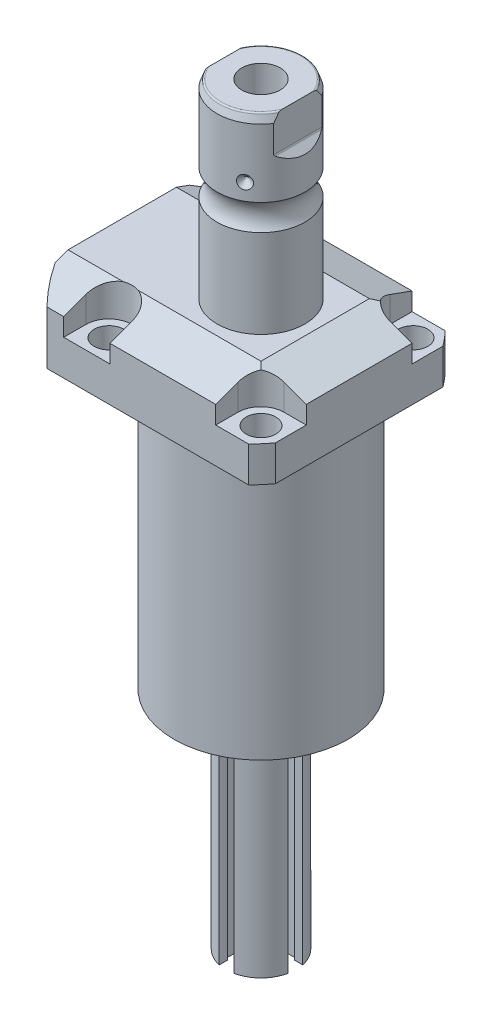
from build123d import *

# Parameters (mm, degrees)
SKETCH1_W                   = 70.866
SKETCH1_H                   = 85.496
EXTRUDE1_DEPTH              = 122.047
SKETCH2_OUTSIDE_W           = 120.498
SKETCH2_OUTSIDE_H           = 105.868
SKETCH2_OUTSIDE_R           = 50.8
CUT_EXTRUDE1_DEPTH          = 123.047
SKETCH3_W                   = 45.1992
SKETCH3_H                   = 97.028
FILLET1_R                   = 0.381
CUT_EXTRUDE2_DEPTH          = 12.243
CUT_EXTRUDE9_START          = -51.063
CUT_EXTRUDE9_DEPTH          = 87.496
CUT_EXTRUDE7_DEPTH          = 36.433
CUT_EXTRUDE7_DEPTH_BACK     = 36.433
SKETCH10_R                  = 1.1811
SKETCH17_W                  = 5.3594
SKETCH17_H                  = 12.776
HOLE1_AT_2_COUNT            = 2
HOLE1_AT_2_PITCH            = 54.864
HOLE1_AT_3_COUNT            = 2
HOLE1_AT_3_PITCH            = 77.589412886
HOLE1_AT_4_COUNT            = 2
HOLE1_AT_4_PITCH            = 54.864
CHAMFER1_SIZE               = 0.635
FILLET2_R                   = 0.635
CIRPATTERN1_COUNT           = 3
CUT_EXTRUDE10_DEPTH         = 36.433
CUT_EXTRUDE10_DEPTH_BACK    = 36.433
SKETCH31_R                  = 1.727203454
SKETCH31_R_2                = 1.727
CUT_EXTRUDE11_DEPTH         = 99.568005
SKETCH32_R                  = 2.705
SKETCH32_R_2                = 2.70510541
EXTRUDE2_DEPTH              = 2.946405893
CUT_EXTRUDE12_DEPTH         = 2.032004064
CUT_EXTRUDE13_DEPTH         = 6.477012954
SKETCH35_W                  = 6.98501397
SKETCH35_H                  = 70.612141224
CUT_EXTRUDE14_DEPTH         = 3.302006604
CIRPATTERN2_COUNT           = 2
CIRPATTERN2_ANGLE           = 90
CIRPATTERN2_COPY_1_DEPTH    = 6.477012954
CIRPATTERN2_COPY_2_SKETCH_W = 6.98501397
CIRPATTERN2_COPY_2_SKETCH_H = 70.612141224
CIRPATTERN2_COPY_2_DEPTH    = 3.302006604


with BuildPart() as part:
    # Sketch1 → Extrude1 (new body)
    with BuildSketch(Plane(origin=(0, 0, 0), x_dir=(0, 0, 1), z_dir=(0, -1, 0))):
        with Locations((0, 7.315)):
            Rectangle(SKETCH1_W, SKETCH1_H)
    extrude(amount=-EXTRUDE1_DEPTH)

    # Sketch2 outside → Cut-Extrude1 (cut, through all)
    with BuildSketch(Plane.XZ):
        with Locations((-7.315, 0)):
            Rectangle(SKETCH2_OUTSIDE_W, SKETCH2_OUTSIDE_H)
        with Locations((-5.4102, 0)):
            Circle(SKETCH2_OUTSIDE_R, mode=Mode.SUBTRACT)
    extrude(amount=-CUT_EXTRUDE1_DEPTH, mode=Mode.SUBTRACT)

    # Sketch3 → Cut-Revolve1 (revolve, cut)
    with BuildSketch(Plane(origin=(0, 0, 0), x_dir=(0, 0, -1), z_dir=(1, 0, 0))):
        with Locations((53.9941, 48.514)):
            Rectangle(SKETCH3_W, SKETCH3_H)
    revolve(axis=Axis((0, -93.345, 0), (0, 1, 0)), mode=Mode.SUBTRACT)

    # Fillet1
    fillet1_edges = [part.edges().sort_by_distance(p)[0] for p in [
        (0, 97.028, 31.3945),
    ]]
    fillet(fillet1_edges, radius=FILLET1_R)

    # Sketch4 → Cut-Extrude2 (cut)
    with BuildSketch(Plane(origin=(0, 122.047, 0), x_dir=(-1, 0, 0), z_dir=(0, 1, 0))):
        with BuildLine():
            Line((-19.1008, -35.433), (-19.1008, -27.432))
            ThreePointArc((-19.1008, -27.432), (-21.540951985, -21.540951985), (-27.432, -19.1008))
            Line((-27.432, -19.1008), (-35.433, -19.1008))
            Line((-35.433, -19.1008), (-35.433, -35.433))
            Line((-35.433, -35.433), (-19.1008, -35.433))
        make_face()
        with BuildLine():
            Line((35.7632, -35.433), (19.1008, -35.433))
            Line((19.1008, -35.433), (19.1008, -27.432))
            ThreePointArc((19.1008, -27.432), (27.432, -19.1008), (35.7632, -27.432))
            Line((35.7632, -27.432), (35.7632, -35.433))
        make_face()
        with BuildLine():
            Line((19.1008, 35.433), (19.1008, 27.432))
            ThreePointArc((19.1008, 27.432), (27.432, 19.1008), (35.7632, 27.432))
            Line((35.7632, 27.432), (35.7632, 35.433))
            Line((35.7632, 35.433), (19.1008, 35.433))
        make_face()
        with BuildLine():
            Line((-27.432, 19.1008), (-35.433, 19.1008))
            Line((-35.433, 19.1008), (-35.433, 35.433))
            Line((-35.433, 35.433), (-19.1008, 35.433))
            Line((-19.1008, 35.433), (-19.1008, 27.432))
            ThreePointArc((-19.1008, 27.432), (-21.540951985, 21.540951985), (-27.432, 19.1008))
        make_face()
    extrude(amount=-CUT_EXTRUDE2_DEPTH, mode=Mode.SUBTRACT)

    # Sketch5 → Cut-Extrude9 (cut)
    with BuildSketch(Plane(origin=(0, 0, 0), x_dir=(0, 0, -1), z_dir=(1, 0, 0)).offset(CUT_EXTRUDE9_START)):
        Polygon((-19.558, 122.047), (-35.433, 116.268972531), (-35.433, 122.047), align=None)
    cut_extrude9 = extrude(amount=CUT_EXTRUDE9_DEPTH, mode=Mode.SUBTRACT)

    # Mirror1: Cut-Extrude9 across plane
    add(cut_extrude9.mirror(Plane.XY), mode=Mode.SUBTRACT)

    # Sketch9 → Cut-Extrude7 (cut, two sides)
    with BuildSketch(Plane.XY) as cut_extrude7_sk:
        Polygon((19.558, 122.047), (35.433, 116.268972531), (35.433, 122.047), align=None)
    extrude(amount=CUT_EXTRUDE7_DEPTH, mode=Mode.SUBTRACT)
    extrude(cut_extrude7_sk.sketch, amount=-CUT_EXTRUDE7_DEPTH_BACK, mode=Mode.SUBTRACT)

    # Sketch20 → Cut-Revolve4 (revolve, cut)
    with BuildSketch(Plane(origin=(-35.0774, 88.9, -18.1102), x_dir=(0, 1, 0), z_dir=(1, 0, 0)), mode=Mode.PRIVATE) as cut_revolve4_sk:
        Polygon((8.128, 38.3413), (9.5758, 38.3413), (9.5758, 35.8902), (10.5918, 35.8902), (10.5918, 33.8836), (21.5646, 33.8836), (21.5646, 32.639), (8.128, 32.639), align=None)
    cut_revolve4 = revolve(cut_revolve4_sk.sketch.rotate(Axis((-35.0774, 81.620304954, 14.5288), (0, 1, 0)), 180), axis=Axis((-35.0774, 81.620304954, 14.5288), (0, 1, 0)), mode=Mode.SUBTRACT)  # turned: the seam where the file's is

    # Mirror10: Cut-Revolve4 across plane
    add(cut_revolve4.mirror(Plane.XY), mode=Mode.SUBTRACT)

    # Sketch15 → Revolve3 (revolve)
    with BuildSketch(Plane(origin=(0, 0, 0), x_dir=(0, 0, -1), z_dir=(1, 0, 0)), mode=Mode.PRIVATE) as revolve3_sk:
        with BuildLine():
            Line((0, 122.047), (15.875, 122.047))
            Line((15.875, 122.047), (15.875, 153.87790643))
            ThreePointArc((15.875, 153.87790643), (14.3256, 158.585), (15.875, 163.29209357))
            Line((15.875, 163.29209357), (15.875, 187.76999416))
            Line((15.875, 187.76999416), (14.81184082, 190.691))
            Line((14.81184082, 190.691), (0, 190.691))
            Line((0, 190.691), (0, 122.047))
        make_face()
    revolve(revolve3_sk.sketch.rotate(Axis((0, 250.290824608, 0), (0, -1, 0)), 180), axis=Axis((0, 250.290824608, 0), (0, -1, 0)))  # turned: the seam where the file's is

    # Sketch17 → Hole1 (revolve, cut)
    with BuildSketch(Plane(origin=(27.432, 109.804, -27.432), x_dir=(0, 0, 1), z_dir=(1, 0, 0))):
        with Locations((2.6797, 6.388)):
            Rectangle(SKETCH17_W, SKETCH17_H)
    hole1 = revolve(axis=Axis((27.432, -0.196, -27.432), (0, 1, 0)), mode=Mode.SUBTRACT)

    # Hole1 at 2: Hole1 ×2
    with Locations(*[(0, 0, i * HOLE1_AT_2_PITCH) for i in range(1, HOLE1_AT_2_COUNT)]):
        add(hole1, mode=Mode.SUBTRACT)

    # Hole1 at 3: Hole1 ×2
    with Locations(*[Vector(-0.707106781, 0, 0.707106781) * (i * HOLE1_AT_3_PITCH) for i in range(1, HOLE1_AT_3_COUNT)]):
        add(hole1, mode=Mode.SUBTRACT)

    # Hole1 at 4: Hole1 ×2
    with Locations(*[(-i * HOLE1_AT_4_PITCH, 0, 0) for i in range(1, HOLE1_AT_4_COUNT)]):
        add(hole1, mode=Mode.SUBTRACT)

    # Chamfer1
    chamfer1_edges = [part.edges().sort_by_distance(p)[0] for p in [
        (-35.0774, 99.4918, 15.7734),
        (-35.0774, 99.4918, -15.7734),
    ]]
    chamfer(chamfer1_edges, length=CHAMFER1_SIZE)

    # Sketch21 → Cut-Revolve5 (revolve, cut)
    with BuildSketch(Plane.XZ.offset(-110.0328)):
        Polygon((-50.063, -1.9304), (-49.809, -1.9304), (-49.809, -6.3246), (-49.0978, -7.0358), (-35.6358, -7.0358), (-35.6358, -12.9794), (-50.063, -12.9794), align=None)
    cut_revolve5 = revolve(axis=Axis((-57.549532301, 110.0328, -12.9794), (1, 0, 0)), mode=Mode.SUBTRACT)

    # Mirror13: Cut-Revolve5 across plane
    add(cut_revolve5.mirror(Plane.XY), mode=Mode.SUBTRACT)

    # Fillet2
    fillet2_edges = [part.edges().sort_by_distance(p)[0] for p in [
        (0, 190.691, -14.81184082),
    ]]
    fillet(fillet2_edges, radius=FILLET2_R)

    # Sketch26 → Cut-Revolve7 (revolve, cut)
    with BuildSketch(Plane.XY, mode=Mode.PRIVATE) as cut_revolve7_sk:
        Polygon((-15.875, 171.686), (-13.462, 169.273), (-15.875, 169.273), align=None)
    cut_revolve7 = revolve(cut_revolve7_sk.sketch.rotate(Axis((-39.772000707, 169.273, 0), (1, 0, 0)), 90), axis=Axis((-39.772000707, 169.273, 0), (1, 0, 0)), mode=Mode.SUBTRACT)  # turned: the seam where the file's is

    # CirPattern1: Cut-Revolve7 ×3 about axis
    cirpattern1_axis = Axis((0, 250.290824608, 0), (0, 1, 0))
    for i in range(1, CIRPATTERN1_COUNT):
        add(cut_revolve7.rotate(cirpattern1_axis, i * 360 / CIRPATTERN1_COUNT), mode=Mode.SUBTRACT)

    # Sketch27 → Hole2 (revolve, cut)
    with BuildSketch(Plane(origin=(0, 190.691, 0), x_dir=(0, 0, 1), z_dir=(1, 0, 0))):
        Polygon((0, 0), (0, 29.566487704), (6.9342, 25.4), (6.9342, 0), align=None)
    revolve(axis=Axis((0, 194.935199587, 0), (0, -1, 0)), mode=Mode.SUBTRACT)

    # Sketch29 → Cut-Extrude10 (cut, two sides)
    with BuildSketch(Plane.XY) as cut_extrude10_sk:
        with BuildLine():
            Line((13.284, 190.691), (13.284, 177.991))
            ThreePointArc((13.284, 177.991), (13.342003912, 177.699394643), (13.507185078, 177.452183558))
            Line((13.507185078, 177.452183558), (15.875, 175.084368636))
            Line((15.875, 175.084368636), (15.875, 190.691))
            Line((15.875, 190.691), (13.284, 190.691))
        make_face()
        with BuildLine():
            Line((-15.875, 190.691), (-13.284, 190.691))
            Line((-13.284, 190.691), (-13.284, 177.991))
            ThreePointArc((-13.284, 177.991), (-13.342003912, 177.699394643), (-13.507185078, 177.452183558))
            Line((-13.507185078, 177.452183558), (-15.875, 175.084368636))
            Line((-15.875, 175.084368636), (-15.875, 190.691))
        make_face()
    extrude(amount=CUT_EXTRUDE10_DEPTH, mode=Mode.SUBTRACT)
    extrude(cut_extrude10_sk.sketch, amount=-CUT_EXTRUDE10_DEPTH_BACK, mode=Mode.SUBTRACT)

    # Sketch30 → Revolve5 (revolve)
    with BuildSketch(Plane.XY, mode=Mode.PRIVATE) as revolve5_sk:
        Polygon((0, 0), (22.22504445, 0), (22.22504445, -2.54000508), (12.7000254, -2.54000508), (12.7000254, -81.28016256), (0, -81.28016256), align=None)
    revolve(revolve5_sk.sketch.rotate(Axis((0, -963.130914712, 0), (0, 1, 0)), 270), axis=Axis((0, -963.130914712, 0), (0, 1, 0)))  # turned: the seam where the file's is

    # Sketch31 → Cut-Extrude11 (cut)
    with BuildSketch(Plane.XZ.offset(2.54000508)):
        with Locations((19.431038862, 0)):
            Circle(SKETCH31_R)
        with Locations((16.827773276, 9.715519431)):
            Circle(SKETCH31_R_2)
        with Locations((9.715519431, 16.827773276)):
            Circle(SKETCH31_R_2)
        with Locations((0, 19.431038862)):
            Circle(SKETCH31_R_2)
        with Locations(Location((-9.715519431, 16.827773276, 0), (0, 0, 90))):  # turned: the seam where the file's is
            Circle(SKETCH31_R_2)
        with Locations(Location((-16.827773276, 9.715519431, 0), (0, 0, 90))):  # turned: the seam where the file's is
            Circle(SKETCH31_R_2)
        with Locations(Location((-19.431038862, 0, 0), (0, 0, 90))):  # turned: the seam where the file's is
            Circle(SKETCH31_R)
        with Locations(Location((16.827773276, -9.715519431, 0), (0, 0, 90))):  # turned: the seam where the file's is
            Circle(SKETCH31_R_2)
        with Locations(Location((9.715519431, -16.827773276, 0), (0, 0, 90))):  # turned: the seam where the file's is
            Circle(SKETCH31_R_2)
        with Locations(Location((0, -19.431038862, 0), (0, 0, 90))):  # turned: the seam where the file's is
            Circle(SKETCH31_R_2)
        with Locations((-9.715519431, -16.827773276)):
            Circle(SKETCH31_R_2)
        with Locations((-16.827773276, -9.715519431)):
            Circle(SKETCH31_R_2)
    extrude(amount=-CUT_EXTRUDE11_DEPTH, mode=Mode.SUBTRACT)

    # Sketch32 → Extrude2 (add)
    with BuildSketch(Plane.XZ.offset(2.54000508)):
        with Locations((19.431038862, 0)):
            Circle(SKETCH32_R)
        with Locations((-9.715519431, 16.827773276)):
            Circle(SKETCH32_R)
        with Locations((-9.715519431, -16.827773276)):
            Circle(SKETCH32_R_2)
    extrude(amount=EXTRUDE2_DEPTH)

    # Sketch33 → Cut-Extrude12 (cut)
    with BuildSketch(Plane.XZ.offset(5.486410973)):
        Polygon((-9.033704626, -18.099961118), (-8.272865039, -16.873398255), (-8.954679844, -15.601210414), (-10.397334236, -15.555585435), (-11.158173823, -16.782148298), (-10.476359018, -18.054336139), align=None)
        Polygon((20.279147066, -1.167923717), (20.866544572, 0.150521391), (20.018436369, 1.318445108), (18.582930659, 1.167923717), (17.995533152, -0.150521391), (18.843641355, -1.318445108), align=None)
        Polygon((-9.715519431, 15.384397604), (-8.465519431, 16.10608544), (-8.465519431, 17.549461113), (-9.715519431, 18.271148949), (-10.965519431, 17.549461113), (-10.965519431, 16.10608544), align=None)
    extrude(amount=-CUT_EXTRUDE12_DEPTH, mode=Mode.SUBTRACT)

    # Sketch34 → Cut-Extrude13 (cut)
    with BuildSketch(Plane(origin=(0, -41.91008382, 12.7000254), x_dir=(-1, 0, 0), z_dir=(0, 0, 1))):
        with BuildLine():
            Line((-2.641605283, -28.95744484), (-2.641605283, 39.37007874))
            Line((-2.641605283, 39.37007874), (2.641605283, 39.37007874))
            Line((2.641605283, 39.37007874), (2.641605283, -28.95744484))
            ThreePointArc((2.641605283, -28.95744484), (0, -34.734562484), (-2.641605283, -28.95744484))
        make_face()
    cut_extrude13 = extrude(amount=-CUT_EXTRUDE13_DEPTH, mode=Mode.SUBTRACT)

    # Sketch35 → Cut-Extrude14 (cut)
    with BuildSketch(Plane.XY.offset(6.223012446)):
        with Locations((0, -45.974091948)):
            Rectangle(SKETCH35_W, SKETCH35_H)
    cut_extrude14 = extrude(amount=CUT_EXTRUDE14_DEPTH, mode=Mode.SUBTRACT)

    # Mirror14: Cut-Extrude13, Cut-Extrude14 across plane
    add(cut_extrude13.mirror(Plane.XY), mode=Mode.SUBTRACT)
    add(cut_extrude14.mirror(Plane.XY), mode=Mode.SUBTRACT)

    # CirPattern2: Cut-Extrude13, Cut-Extrude14 ×2 about axis
    cirpattern2_axis = Axis((0, 0, 0), (0, -1, 0))
    add([cut_extrude13.rotate(cirpattern2_axis, i * CIRPATTERN2_ANGLE / (CIRPATTERN2_COUNT - 1)) for i in range(1, CIRPATTERN2_COUNT)], mode=Mode.SUBTRACT)
    add([cut_extrude14.rotate(cirpattern2_axis, i * CIRPATTERN2_ANGLE / (CIRPATTERN2_COUNT - 1)) for i in range(1, CIRPATTERN2_COUNT)], mode=Mode.SUBTRACT)

    # CirPattern2 copy 1 sketch → CirPattern2 copy 1 (cut)
    with BuildSketch(Plane(origin=(12.7000254, -41.91008382, 0), x_dir=(0, 0, -1), z_dir=(1, 0, 0))):
        with BuildLine():
            Line((-2.641605283, 28.95744484), (-2.641605283, -39.37007874))
            Line((-2.641605283, -39.37007874), (2.641605283, -39.37007874))
            Line((2.641605283, -39.37007874), (2.641605283, 28.95744484))
            ThreePointArc((2.641605283, 28.95744484), (0, 34.734562484), (-2.641605283, 28.95744484))
        make_face()
    extrude(amount=-CIRPATTERN2_COPY_1_DEPTH, mode=Mode.SUBTRACT)

    # CirPattern2 copy 2 sketch → CirPattern2 copy 2 (cut)
    with BuildSketch(Plane(origin=(6.223012446, 0, 0), x_dir=(0, 0, 1), z_dir=(1, 0, 0))):
        with Locations((0, 45.974091948)):
            Rectangle(CIRPATTERN2_COPY_2_SKETCH_W, CIRPATTERN2_COPY_2_SKETCH_H)
    extrude(amount=CIRPATTERN2_COPY_2_DEPTH, mode=Mode.SUBTRACT)


with BuildPart() as body_2:
    # Sketch10 → Revolve4 (revolve)
    with BuildSketch(Plane(origin=(-35.0774, 88.9, -18.1102), x_dir=(0, 1, 0), z_dir=(1, 0, 0))):
        with Locations((8.3947, 8.1026)):
            Circle(SKETCH10_R)
    revolve(axis=Axis((-35.0774, 87.86749, -14.5288), (0, 1, 0)))


with BuildPart() as body_3:
    # Mirror12: mirrored copy
    add(body_2.part.mirror(Plane.XY))


solid = Compound([part.part, body_2.part, body_3.part])
